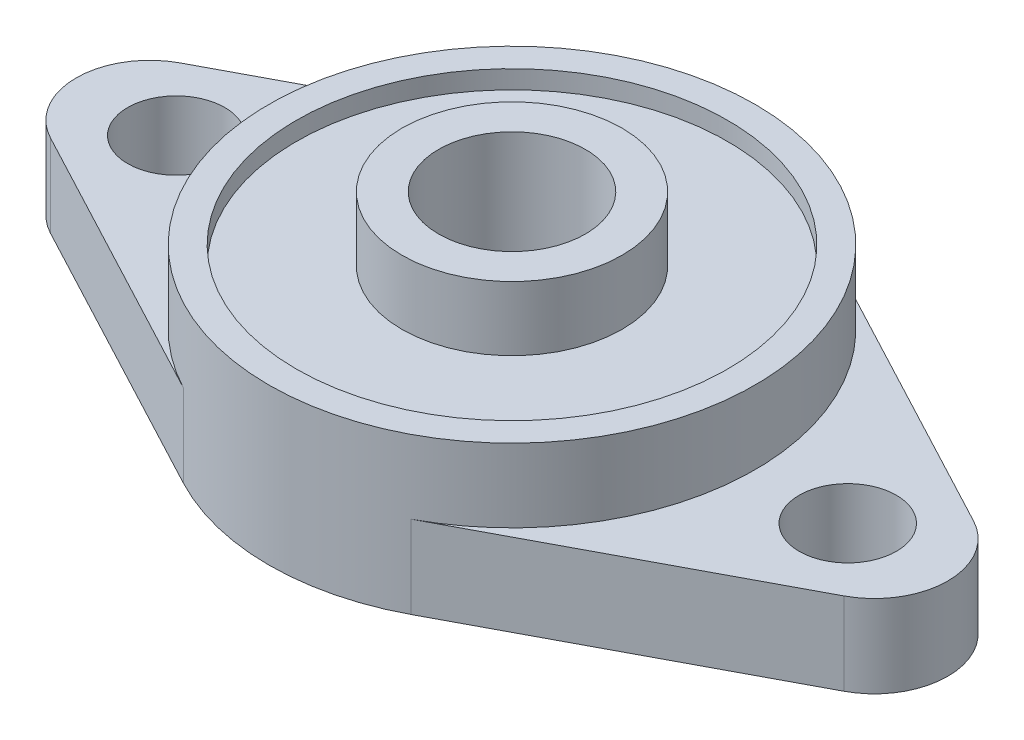
from build123d import *

# Parameters (mm, degrees)
SKETCH1_R           = 2.65
SKETCH1_R_2         = 4
BOSS_EXTRUDE1_DEPTH = 4.5
SKETCH2_R           = 13.25
SKETCH2_R_2         = 4
BOSS_EXTRUDE2_DEPTH = 4
SKETCH3_R           = 6
SKETCH3_R_2         = 4
BOSS_EXTRUDE3_DEPTH = 2.5
SKETCH4_R           = 11.75
SKETCH4_R_2         = 6
CUT_EXTRUDE1_DEPTH  = 1


with BuildPart() as part:
    # Sketch1 → Boss-Extrude1 (new body)
    with BuildSketch(Plane(origin=(0, 0, 0), x_dir=(1, 0, 0), z_dir=(0, 1, 0))):
        with BuildLine():
            Line((6.205696203, 11.706913967), (21.623417722, 3.534162707))
            ThreePointArc((21.623417722, 3.534162707), (23.75, 0), (21.623417722, -3.534162707))
            Line((21.623417722, -3.534162707), (6.205696203, -11.706913967))
            ThreePointArc((6.205696203, -11.706913967), (0, -13.25), (-6.205696203, -11.706913967))
            Line((-6.205696203, -11.706913967), (-21.623417722, -3.534162707))
            ThreePointArc((-21.623417722, -3.534162707), (-23.75, 0), (-21.623417722, 3.534162707))
            Line((-21.623417722, 3.534162707), (-6.205696203, 11.706913967))
            ThreePointArc((-6.205696203, 11.706913967), (0, 13.25), (6.205696203, 11.706913967))
        make_face()
        with Locations((-18.3, 0)):
            Circle(SKETCH1_R, mode=Mode.SUBTRACT)
        with Locations((18.3, 0)):
            Circle(SKETCH1_R, mode=Mode.SUBTRACT)
        Circle(SKETCH1_R_2, mode=Mode.SUBTRACT)
    extrude(amount=BOSS_EXTRUDE1_DEPTH)

    # Sketch2 → Boss-Extrude2 (add)
    with BuildSketch(Plane(origin=(0, 4.5, 0), x_dir=(1, 0, 0), z_dir=(0, 1, 0))):
        Circle(SKETCH2_R)
        Circle(SKETCH2_R_2, mode=Mode.SUBTRACT)
    extrude(amount=BOSS_EXTRUDE2_DEPTH)

    # Sketch3 → Boss-Extrude3 (add)
    with BuildSketch(Plane(origin=(0, 8.5, 0), x_dir=(1, 0, 0), z_dir=(0, 1, 0))):
        Circle(SKETCH3_R)
        Circle(SKETCH3_R_2, mode=Mode.SUBTRACT)
    extrude(amount=BOSS_EXTRUDE3_DEPTH)

    # Sketch4 → Cut-Extrude1 (cut)
    with BuildSketch(Plane(origin=(0, 8.5, 0), x_dir=(1, 0, 0), z_dir=(0, 1, 0))):
        Circle(SKETCH4_R)
        Circle(SKETCH4_R_2, mode=Mode.SUBTRACT)
    extrude(amount=-CUT_EXTRUDE1_DEPTH, mode=Mode.SUBTRACT)


solid = part.part
